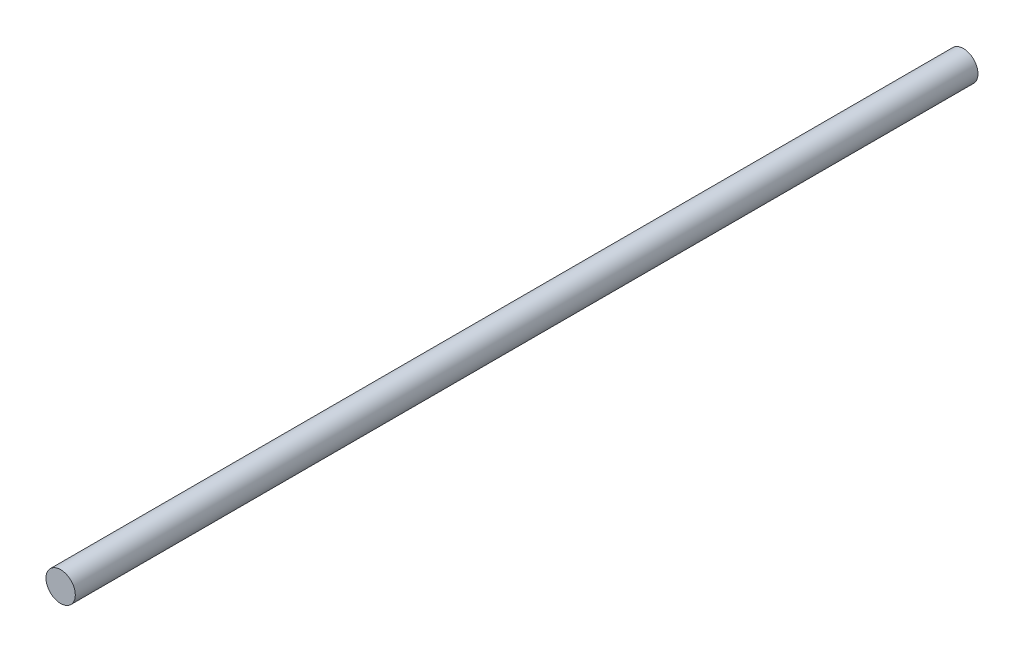
from build123d import *

# Parameters (mm, degrees)
SKETCH1_R           = 0.8255
BOSS_EXTRUDE1_DEPTH = 50.8


with BuildPart() as part:
    # Sketch1 → Boss-Extrude1 (new body)
    with BuildSketch(Plane.XY):
        Circle(SKETCH1_R)
    extrude(amount=BOSS_EXTRUDE1_DEPTH)


solid = part.part
